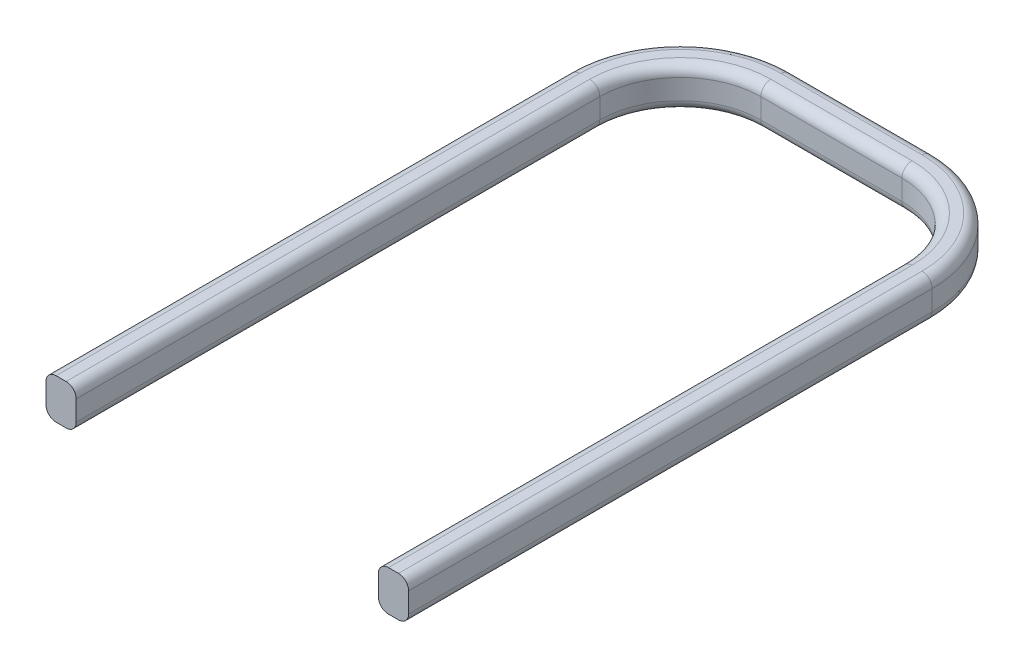
from build123d import *

# Parameters (mm, degrees)
SKETCH2_W = 0.75
SKETCH2_H = 1
FILLET1_R = 0.25


with BuildPart() as part:
    # Sweep1: sweep along a path in Sketch1
    with BuildLine(Plane(origin=(0, 0, 0), x_dir=(1, 0, 0), z_dir=(0, 1, 0))) as sweep1_path:
        Line((-3.95, 0), (-3.95, 13))
        ThreePointArc((-3.95, 13), (-3.364213562, 14.414213562), (-1.95, 15))
        Line((-1.95, 15), (1.553078387, 15))
        ThreePointArc((1.553078387, 15), (2.96729195, 14.414213562), (3.553078387, 13))
        Line((3.553078387, 13), (3.553078387, 0))
    # Sketch2 → Sweep1 (sweep)
    with BuildSketch(Plane.XY):
        with Locations((-4.325, 0.5)):
            Rectangle(SKETCH2_W, SKETCH2_H)
    sweep(path=sweep1_path.line)

    # Fillet1
    fillet1_edges = [part.edges().sort_by_distance(p)[0] for p in [
        (-3.364213562, 1, -14.414213562),
        (-3.894543648, 1, -14.944543648),
        (-3.894543648, 0, -14.944543648),
        (-3.364213562, 0, -14.414213562),
        (-0.198460806, 1, -15),
        (-0.198460806, 1, -15.75),
        (-0.198460806, 0, -15.75),
        (-0.198460806, 0, -15),
        (2.96729195, 1, -14.414213562),
        (3.497622036, 1, -14.944543648),
        (3.497622036, 0, -14.944543648),
        (2.96729195, 0, -14.414213562),
        (3.553078387, 1, -6.5),
        (4.303078387, 1, -6.5),
        (4.303078387, 0, -6.5),
        (3.553078387, 0, -6.5),
        (-3.95, 0, -6.5),
        (-4.7, 0, -6.5),
        (-4.7, 1, -6.5),
        (-3.95, 1, -6.5),
    ]]
    fillet(fillet1_edges, radius=FILLET1_R)


solid = part.part
